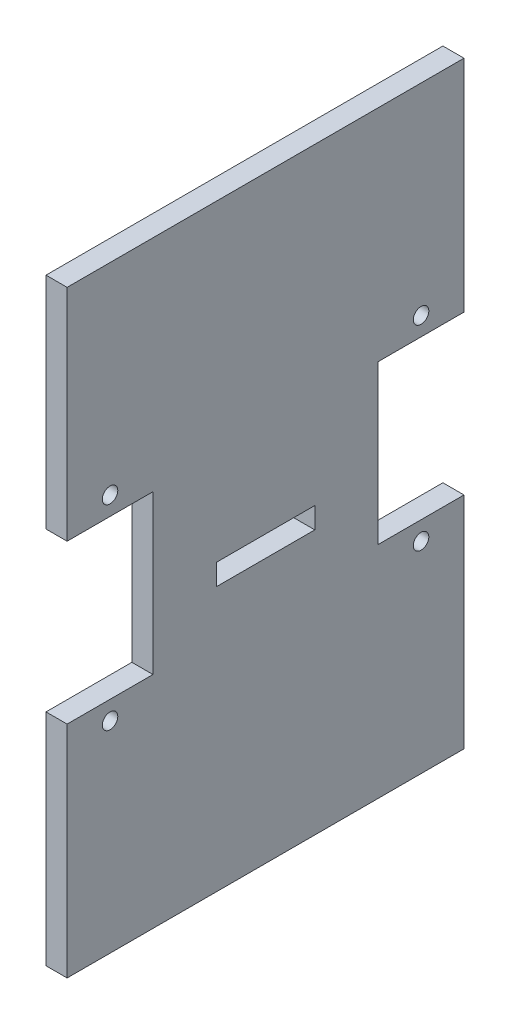
from build123d import *

# Parameters (mm, degrees)
SKETCH1_R           = 1.1
BOSS_EXTRUDE1_DEPTH = 3
SKETCH2_W           = 14
SKETCH2_H           = 3
CUT_EXTRUDE1_DEPTH  = 3


with BuildPart() as part:
    # Sketch1 → Boss-Extrude1 (new body)
    with BuildSketch(Plane(origin=(0, 0, 0), x_dir=(0, 0, -1), z_dir=(1, 0, 0))):
        Polygon((-28.2, -42.5), (28.2, -42.5), (28.2, -11.25), (16, -11.25), (16, 11.25), (28.2, 11.25), (28.2, 42.5), (-28.2, 42.5), (-28.2, 11.25), (-16, 11.25), (-16, -11.25), (-28.2, -11.25), align=None)
        with Locations((22.1, 13.9)):
            Circle(SKETCH1_R, mode=Mode.SUBTRACT)
        with Locations((22.1, -13.9)):
            Circle(SKETCH1_R, mode=Mode.SUBTRACT)
        with Locations((-22.1, -13.9)):
            Circle(SKETCH1_R, mode=Mode.SUBTRACT)
        with Locations((-22.1, 13.9)):
            Circle(SKETCH1_R, mode=Mode.SUBTRACT)
    extrude(amount=BOSS_EXTRUDE1_DEPTH)

    # Sketch2 → Cut-Extrude1 (cut)
    with BuildSketch(Plane(origin=(3, 0, 0), x_dir=(0, 0, -1), z_dir=(1, 0, 0))):
        with Locations((0, -3.45)):
            Rectangle(SKETCH2_W, SKETCH2_H)
    extrude(amount=-CUT_EXTRUDE1_DEPTH, mode=Mode.SUBTRACT)


solid = part.part
